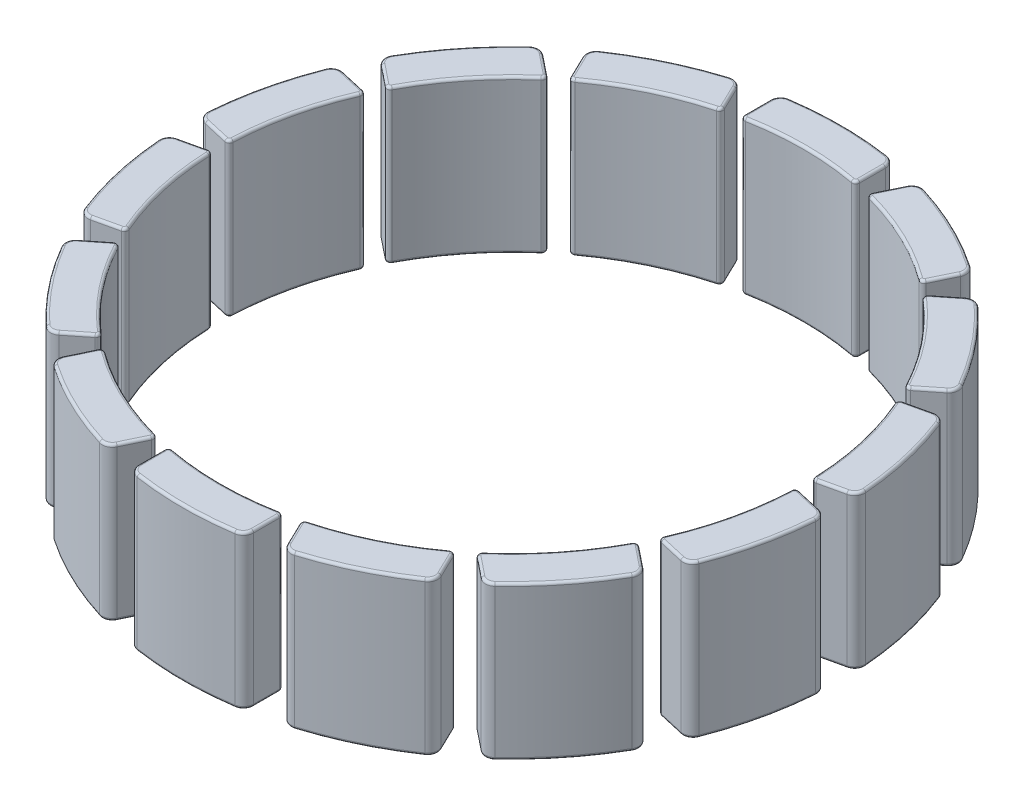
from build123d import *

# Parameters (mm, degrees)
SALIENTE_EXTRUIR1_DEPTH = 6
REDONDEO1_R             = 0.1
MATRIZC3_COUNT          = 14


with BuildPart() as part:
    # Croquis1 → Saliente-Extruir1 (new body)
    with BuildSketch(Plane(origin=(0, 0, 0), x_dir=(1, 0, 0), z_dir=(0, 1, 0))):
        with BuildLine():
            Line((-2.25, -11.357486518), (-2.25, -12.362342011))
            ThreePointArc((-2.25, -12.362342011), (-2.153051151, -12.623416713), (-1.9092, -12.757936955))
            ThreePointArc((-1.9092, -12.757936955), (0, -12.9), (1.9092, -12.757936955))
            ThreePointArc((1.9092, -12.757936955), (2.153051151, -12.623416713), (2.25, -12.362342011))
            Line((2.25, -12.362342011), (2.25, -11.357486518))
            ThreePointArc((2.25, -11.357486518), (2.195940322, -11.2421806), (2.072727273, -11.209986693))
            ThreePointArc((2.072727273, -11.209986693), (0, -11.4), (-2.072727273, -11.209986693))
            ThreePointArc((-2.072727273, -11.209986693), (-2.195940322, -11.2421806), (-2.25, -11.357486518))
        make_face()
    extrude(amount=SALIENTE_EXTRUIR1_DEPTH)

    # Redondeo1
    redondeo1_edges = [part.edges().sort_by_distance(p)[0] for p in [
        (2.153051151, 6, 12.623416713),
        (0, 0, 12.9),
        (-2.153051151, 0, 12.623416713),
        (2.25, 6, 11.859914264),
        (2.195940322, 6, 11.2421806),
        (0, 6, 11.4),
        (-2.195940322, 6, 11.2421806),
        (-2.25, 6, 11.859914264),
        (-2.153051151, 6, 12.623416713),
        (0, 6, 12.9),
        (-2.25, 0, 11.859914264),
        (-2.195940322, 0, 11.2421806),
        (0, 0, 11.4),
        (2.195940322, 0, 11.2421806),
        (2.25, 0, 11.859914264),
        (2.153051151, 0, 12.623416713),
    ]]
    fillet(redondeo1_edges, radius=REDONDEO1_R)


with BuildPart() as matrizc3_1:
    # MatrizC3: pattern copy
    add(part.part.rotate(Axis((0, 0, 0), (0, 1, 0)), 1 * 360 / MATRIZC3_COUNT))


with BuildPart() as matrizc3_2:
    # MatrizC3: pattern copy
    add(part.part.rotate(Axis((0, 0, 0), (0, 1, 0)), 2 * 360 / MATRIZC3_COUNT))


with BuildPart() as matrizc3_3:
    # MatrizC3: pattern copy
    add(part.part.rotate(Axis((0, 0, 0), (0, 1, 0)), 3 * 360 / MATRIZC3_COUNT))


with BuildPart() as matrizc3_4:
    # MatrizC3: pattern copy
    add(part.part.rotate(Axis((0, 0, 0), (0, 1, 0)), 4 * 360 / MATRIZC3_COUNT))


with BuildPart() as matrizc3_5:
    # MatrizC3: pattern copy
    add(part.part.rotate(Axis((0, 0, 0), (0, 1, 0)), 5 * 360 / MATRIZC3_COUNT))


with BuildPart() as matrizc3_6:
    # MatrizC3: pattern copy
    add(part.part.rotate(Axis((0, 0, 0), (0, 1, 0)), 6 * 360 / MATRIZC3_COUNT))


with BuildPart() as matrizc3_7:
    # MatrizC3: pattern copy
    add(part.part.rotate(Axis((0, 0, 0), (0, 1, 0)), 7 * 360 / MATRIZC3_COUNT))


with BuildPart() as matrizc3_8:
    # MatrizC3: pattern copy
    add(part.part.rotate(Axis((0, 0, 0), (0, 1, 0)), 8 * 360 / MATRIZC3_COUNT))


with BuildPart() as matrizc3_9:
    # MatrizC3: pattern copy
    add(part.part.rotate(Axis((0, 0, 0), (0, 1, 0)), 9 * 360 / MATRIZC3_COUNT))


with BuildPart() as matrizc3_10:
    # MatrizC3: pattern copy
    add(part.part.rotate(Axis((0, 0, 0), (0, 1, 0)), 10 * 360 / MATRIZC3_COUNT))


with BuildPart() as matrizc3_11:
    # MatrizC3: pattern copy
    add(part.part.rotate(Axis((0, 0, 0), (0, 1, 0)), 11 * 360 / MATRIZC3_COUNT))


with BuildPart() as matrizc3_12:
    # MatrizC3: pattern copy
    add(part.part.rotate(Axis((0, 0, 0), (0, 1, 0)), 12 * 360 / MATRIZC3_COUNT))


with BuildPart() as matrizc3_13:
    # MatrizC3: pattern copy
    add(part.part.rotate(Axis((0, 0, 0), (0, 1, 0)), 13 * 360 / MATRIZC3_COUNT))


solid = Compound([part.part, matrizc3_1.part, matrizc3_2.part, matrizc3_3.part, matrizc3_4.part, matrizc3_5.part, matrizc3_6.part, matrizc3_7.part, matrizc3_8.part, matrizc3_9.part, matrizc3_10.part, matrizc3_11.part, matrizc3_12.part, matrizc3_13.part])
